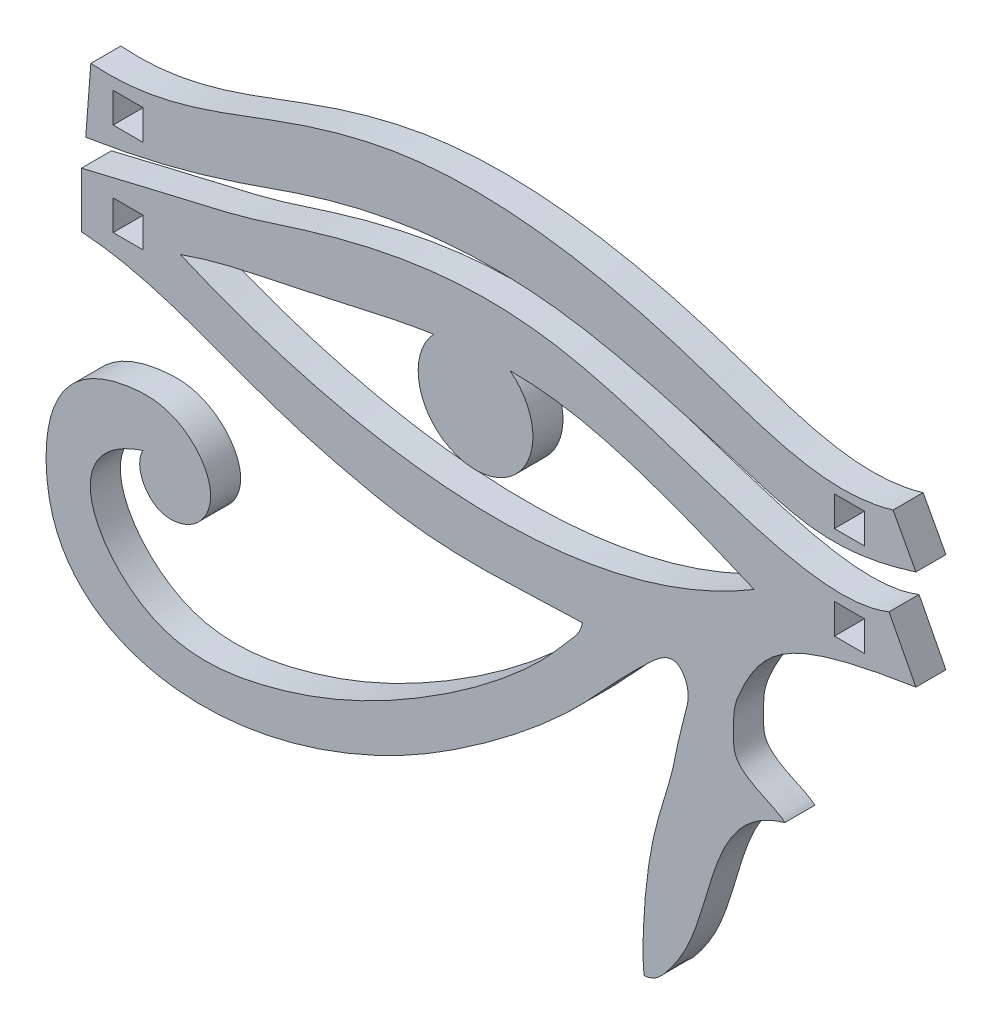
from build123d import *

# Parameters (mm, degrees)
SKETCH1_W           = 3
SKETCH1_H           = 3
SKETCH1_R           = 5.727
BOSS_EXTRUDE2_DEPTH = 3


with BuildPart() as part:
    # Sketch1 → Boss-Extrude2 (new body)
    with BuildSketch(Plane.XY):
        with BuildLine():
            Line((-39.735208654, 21.641251441), (-40.247153197, 14.997323734))
            add(Edge.make_bspline(
                [(-40.247153197, 14.997323734), (-34.62825003, 15.87403203), (-27.587704705, 17.671279001), (-12.539744649, 23.206955843), (4.928810631, 25.662158529), (26.210335755, 18.820760711), (34.992185318, 16.386398189), (42.645909195, 18.849534024)],
                knots=[0, 0, 0, 0, 0.190920113, 0.269409309, 0.566346795, 0.808778622, 1, 1, 1, 1], degree=3))
            Line((42.645909195, 18.849534024), (40.36651253, 23.070880184))
            add(Edge.make_bspline(
                [(-39.735208654, 21.641251441), (-32.568126745, 21.070008089), (-22.653060763, 25.974629263), (-2.659347844, 31.368297936), (18.193707525, 27.773761151), (33.422654754, 21.003976474), (40.36651253, 23.070880184)],
                knots=[0, 0, 0, 0, 0.252986267, 0.399517659, 0.752994495, 1, 1, 1, 1], degree=3))
        make_face()
        with Locations((36.01, 20.034563675)):
            Rectangle(SKETCH1_W, SKETCH1_H, mode=Mode.SUBTRACT)
        with Locations((-36.012247136, 18.918945956)):
            Rectangle(SKETCH1_W, SKETCH1_H, mode=Mode.SUBTRACT)
        with Locations((-1.324074505, 11.417629962)):
            Circle(SKETCH1_R)
        with BuildLine():
            add(Edge.make_bspline(
                [(15.4942315, -29.623218856), (16.565576888, -29.572026894), (18.160910676, -27.830048406), (22.632300397, -20.631140048), (22.302805521, -11.392159272), (29.558885472, -9.367458068)],
                knots=[0, 0, 0, 0, 0.115959685, 0.26146034, 1, 1, 1, 1], degree=3))
            add(Edge.make_bspline(
                [(29.558885472, -9.367458068), (28.497634502, -8.354929853), (24.356434711, -7.51994313), (24.467890836, -4.051531783), (24.384410992, -1.927214513), (27.290163975, 4.829909999), (30.405288982, 6.966232651), (42.645909195, 8.891202321)],
                knots=[0, 0, 0, 0, 0.195150472, 0.243887749, 0.314831388, 0.390442613, 1, 1, 1, 1], degree=3))
            Line((42.645909195, 8.891202321), (39.963554874, 14.063221425))
            add(Edge.make_bspline(
                [(-40.675899247, 12.109737121), (-35.853757112, 13.313896746), (-31.038744645, 14.350107137), (-23.595136834, 16.184548075), (-13.344507438, 19.690293695), (9.49689031, 24.386724448), (31.468241937, 10.606069745), (39.963554874, 14.063221425)],
                knots=[0, 0, 0, 0, 0.177934146, 0.205598939, 0.276647929, 0.570643389, 1, 1, 1, 1], degree=3))
            Line((-40.675899247, 12.109737121), (-40.675899247, 6.611562481))
            add(Edge.make_bspline(
                [(-40.675899247, 6.611562481), (-33.256070649, 6.151237254), (-24.717261106, 1.715495653), (-14.52875391, -0.855518956), (-3.899913287, -3.196210069), (2.935198899, -2.305316091), (9.341587755, -2.191664051)],
                knots=[0, 0, 0, 0, 0.402368515, 0.521970413, 0.581733562, 1, 1, 1, 1], degree=3))
            add(Edge.make_bspline(
                [(9.341587755, -2.191664051), (9.171976352, -3.230965578), (7.87888592, -4.494188485), (5.820882185, -7.011496658), (1.177530919, -11.420960971), (-8.020871994, -17.973830822), (-20.158575556, -23.696178354), (-36.4369351, -25.62839184), (-43.69685819, -12.257016702), (-34.532828227, -9.228576512)],
                knots=[0, 0, 0, 0, 0.043943745, 0.077470884, 0.143724453, 0.324672265, 0.571491462, 0.735829433, 1, 1, 1, 1], degree=3))
            add(Edge.make_bspline(
                [(-34.532828227, -9.228576512), (-35.402725489, -10.813581102), (-33.669464915, -14.602106386), (-28.84130211, -13.311835114), (-27.114806594, -9.394716352), (-29.376005067, -5.618404386), (-32.665807986, -4.211243438), (-39.171116267, -4.417906406), (-44.853605672, -7.778244917), (-43.414596744, -27.154204243), (-28.173475187, -31.530386438), (-8.248104235, -22.672369128), (-1.161942153, -18.164763244), (4.300853672, -13.961830357), (10.277228111, -8.488715466), (12.369027107, -5.708948151), (17.527490489, -0.870825375), (19.211042508, -0.693635912), (20.128300882, -2.899635218), (19.303679613, -5.986259498), (18.868895998, -7.777535397), (18.269529569, -10.972607546), (17.466544471, -13.410601213), (15.457798347, -20.330609147), (15.239900751, -27.733650768), (15.4942315, -29.623218856)],
                knots=[0, 0, 0, 0, 0.060282461, 0.104630683, 0.143020736, 0.196105475, 0.239876929, 0.264242011, 0.420254706, 0.464597423, 0.663326468, 0.692483797, 0.731329578, 0.776341021, 0.787877665, 0.84016064, 0.847806372, 0.857799612, 0.869418987, 0.873546303, 0.896236498, 0.901934609, 0.924829299, 0.934922021, 1, 1, 1, 1], degree=3))
        make_face()
        with Locations((-36.012247136, 9.618945956)):
            Rectangle(SKETCH1_W, SKETCH1_H, mode=Mode.SUBTRACT)
        with Locations((36.01, 10.734563675)):
            Rectangle(SKETCH1_W, SKETCH1_H, mode=Mode.SUBTRACT)
        with BuildLine():
            add(Edge.make_bspline(
                [(-30.797689617, 9.582879193), (-12.943725481, 1.857392245), (9.042517133, -1.264323498), (26.498769683, 9.267126142)],
                knots=[0, 0, 0, 0, 1, 1, 1, 1], degree=3))
            add(Edge.make_bspline(
                [(-30.797689617, 9.582879193), (-26.992593928, 10.961003103), (-15.082042671, 13.064516297), (4.600878335, 18.719927449), (19.783953887, 12.042926804), (26.498769683, 9.267126142)],
                knots=[0, 0, 0, 0, 0.204186925, 0.621088096, 1, 1, 1, 1], degree=3))
        make_face(mode=Mode.SUBTRACT)
        with BuildLine():
            ThreePointArc((-5.499817885, 15.337029945), (-3.431685316, 6.092547271), (4.402925495, 11.417629962))
            ThreePointArc((4.402925495, 11.417629962), (3.799226134, 13.976989172), (2.115403385, 15.996769712))
            add(Edge.make_bspline(
                [(-5.499817885, 15.337029945), (-2.957503959, 15.734922901), (-0.416315685, 15.992476399), (2.115403385, 15.996769712)],
                knots=[0.437555532, 0.437555532, 0.437555532, 0.437555532, 0.567810962, 0.567810962, 0.567810962, 0.567810962], degree=3))
        make_face()
        with BuildLine():
            add(Edge.make_bspline(
                [(-5.499817885, 15.337029945), (-2.957503959, 15.734922901), (-0.416315685, 15.992476399), (2.115403385, 15.996769712)],
                knots=[0.437555532, 0.437555532, 0.437555532, 0.437555532, 0.567810962, 0.567810962, 0.567810962, 0.567810962], degree=3))
            ThreePointArc((2.115403385, 15.996769712), (-1.818377911, 17.123258161), (-5.499817885, 15.337029945))
        make_face()
    extrude(amount=BOSS_EXTRUDE2_DEPTH)


solid = part.part
